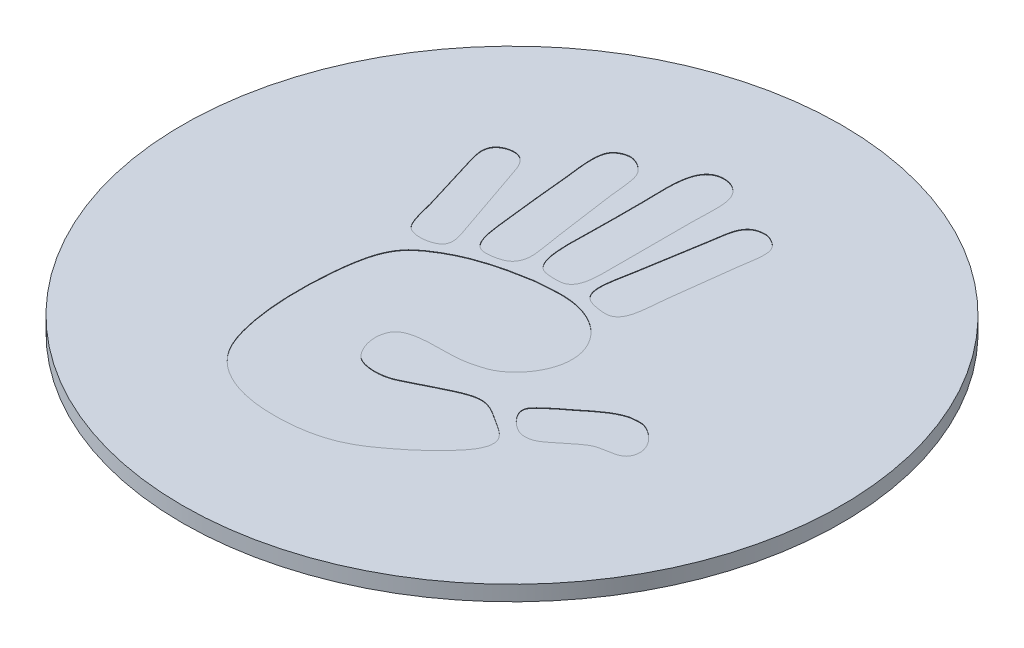
from build123d import *

# Parameters (mm, degrees)
BOSS_EXTRUDE1_DEPTH = 0.762
CUT_EXTRUDE1_DEPTH  = 1.7620001
SKETCH5_W           = 66.957021014
SKETCH5_H           = 66.705618862
SKETCH5_R           = 16.51
CUT_EXTRUDE2_DEPTH  = 1.7620001
SKETCH7_R           = 16.51
BOSS_EXTRUDE3_DEPTH = 0.7366
CUT_EXTRUDE3_DEPTH  = 0.0254


with BuildPart() as part:
    # Sketch2 → Boss-Extrude1 (new body)
    with BuildSketch(Plane(origin=(0, 0, 0), x_dir=(1, 0, 0), z_dir=(0, 1, 0))):
        with BuildLine():
            Line((-23.635380091, -2.180304698), (-14.813443938, -18.5313878))
            Line((-14.813443938, -18.5313878), (-14.014451475, -18.100305623))
            ThreePointArc((-14.014451475, -18.100305623), (-11.556001338, -17.46115621), (-9.0807022, -18.031579938))
            ThreePointArc((-9.0807022, -18.031579938), (9.738603257, -17.694307675), (20.10418165, -1.983330779))
            ThreePointArc((20.10418165, -1.983330779), (20.847910502, 0.100653492), (22.48315193, 1.591327339))
            Line((22.48315193, 1.591327339), (23.635380091, 2.212991555))
            Line((23.635380091, 2.212991555), (14.83107955, 18.5313878))
            Line((14.83107955, 18.5313878), (13.915099114, 18.037186842))
            ThreePointArc((13.915099114, 18.037186842), (11.560425994, 17.428305356), (9.192581241, 17.983763181))
            ThreePointArc((9.192581241, 17.983763181), (-9.768999321, 17.667810878), (-20.106557894, 1.76887236))
            add(Edge.make_bspline(
                [(-20.106557894, 1.76887236), (-20.133827845, 1.458762192), (-20.197178405, 1.153791884), (-20.394094427, 0.565769964), (-20.525315031, 0.288238595), (-20.771108397, -0.10343033), (-20.8619269, -0.230562624), (-21.056974515, -0.471231729), (-21.161207981, -0.585030389), (-21.49390379, -0.906948796), (-21.743736349, -1.096210535), (-22.013245148, -1.252214934)],
                knots=[0, 0, 0, 0, 0.25, 0.25, 0.5, 0.5, 0.625, 0.625, 0.75, 0.75, 1, 1, 1, 1], degree=3))
            add(Edge.make_bspline(
                [(-23.635380091, -2.180304698), (-22.82042052, -1.719446091), (-22.013245148, -1.252214934)],
                knots=[4.793026226, 4.793026226, 4.793026226, 4.83347732, 4.83347732, 4.83347732], degree=2, weights=[1, 0.999795471, 1]))
        make_face()
    extrude(amount=BOSS_EXTRUDE1_DEPTH)

    # Sketch3 → Cut-Extrude1 (cut, through all)
    with BuildSketch(Plane(origin=(0, 0.762, 0), x_dir=(1, 0, 0), z_dir=(0, 1, 0))):
        with BuildLine():
            add(Edge.make_bspline(
                [(-1.128188655, 2.734174481), (-1.869108604, 3.092326844), (-1.6328438, 5.069210065), (-1.6328438, 6.157103035), (-1.6328438, 6.906601277), (-1.6328438, 7.565510675), (-1.6328438, 8.131867521), (-1.6328438, 9.344283549), (-1.85537989, 11.072844124), (-0.755170695, 11.225651435)],
                knots=[5, 5, 5, 5, 6, 6, 6, 7, 7, 7, 8, 8, 8, 8], degree=3))
            add(Edge.make_bspline(
                [(-0.755170695, 11.225651435), (-0.219595798, 11.300048321), (0.250126056, 10.989955072), (0.407739278, 10.501578013)],
                knots=[0, 0, 0, 0, 1, 1, 1, 1], degree=3))
            add(Edge.make_bspline(
                [(0.407739278, 10.501578013), (0.565593658, 10.012511936), (0.473575097, 9.222964431), (0.473575097, 8.460994935), (0.473575097, 7.070002264), (0.473575097, 5.693186171), (0.473575097, 4.248157142), (0.473575097, 3.45375205), (0.396094848, 2.864450853), (-0.053042547, 2.690283935)],
                knots=[1, 1, 1, 1, 2, 2, 2, 3, 3, 3, 4, 4, 4, 4], degree=3))
            add(Edge.make_bspline(
                [(-0.053042547, 2.690283935), (-0.22901814, 2.622053774), (-0.871856156, 2.61027154), (-1.128188655, 2.734174481)],
                knots=[4, 4, 4, 4, 5, 5, 5, 5], degree=3))
        make_face()
        with BuildLine():
            add(Edge.make_bspline(
                [(1.746194208, 8.219631386), (1.878520413, 9.06256068), (1.899053196, 9.833005117), (2.799395044, 9.865268457)],
                knots=[7, 7, 7, 7, 8, 8, 8, 8], degree=3))
            add(Edge.make_bspline(
                [(2.799395044, 9.865268457), (3.075416276, 9.875155888), (3.532649651, 9.643886476), (3.655122876, 9.316722767)],
                knots=[0, 0, 0, 0, 1, 1, 1, 1], degree=3))
            add(Edge.make_bspline(
                [(3.655122876, 9.316722767), (3.806362668, 8.912750604), (3.630524878, 8.249758766), (3.567376236, 7.714959015)],
                knots=[1, 1, 1, 1, 2, 2, 2, 2], degree=3))
            add(Edge.make_bspline(
                [(3.567376236, 7.714959015), (3.440975599, 6.644653269), (3.312576806, 5.620391255), (3.172430229, 4.555339283)],
                knots=[2, 2, 2, 2, 3, 3, 3, 3], degree=3))
            add(Edge.make_bspline(
                [(3.172430229, 4.555339283), (3.072246786, 3.794162159), (3.134671958, 2.612114667), (2.470284855, 2.426992339)],
                knots=[3, 3, 3, 3, 4, 4, 4, 4], degree=3))
            add(Edge.make_bspline(
                [(2.470284855, 2.426992339), (2.231263973, 2.3603986), (1.566980223, 2.44745622), (1.307357656, 2.624465343)],
                knots=[4, 4, 4, 4, 5, 5, 5, 5], degree=3))
            add(Edge.make_bspline(
                [(1.307357656, 2.624465343), (0.7186249, 3.025905359), (1.079119929, 4.108475653), (1.197665743, 4.90641197)],
                knots=[5, 5, 5, 5, 6, 6, 6, 6], degree=3))
            add(Edge.make_bspline(
                [(1.197665743, 4.90641197), (1.342945516, 5.884544126), (1.593231868, 7.245461093), (1.746194208, 8.219631386)],
                knots=[6, 6, 6, 6, 7, 7, 7, 7], degree=3))
        make_face()
        with BuildLine():
            add(Edge.make_bspline(
                [(-4.616935802, 9.470305225), (-4.488709263, 9.680990178), (-4.227105765, 9.812661815), (-3.980626246, 9.843323185)],
                knots=[9, 9, 9, 9, 10, 10, 10, 10], degree=3))
            add(Edge.make_bspline(
                [(-3.980626246, 9.843323185), (-3.603990933, 9.890176514), (-3.071361594, 9.539689494), (-2.927408185, 9.141195036)],
                knots=[0, 0, 0, 0, 1, 1, 1, 1], degree=3))
            add(Edge.make_bspline(
                [(-2.927408185, 9.141195036), (-2.783592579, 8.743062314), (-2.772103178, 8.125425188), (-2.707989908, 7.671085695)],
                knots=[1, 1, 1, 1, 2, 2, 2, 2], degree=3))
            add(Edge.make_bspline(
                [(-2.707989908, 7.671085695), (-2.57624937, 6.737429752), (-2.408783168, 5.678079417), (-2.291098629, 4.708938967)],
                knots=[2, 2, 2, 2, 3, 3, 3, 3], degree=3))
            add(Edge.make_bspline(
                [(-2.291098629, 4.708938967), (-2.23175682, 4.22025185), (-2.10578682, 3.719748047), (-2.071680353, 3.260774899)],
                knots=[3, 3, 3, 3, 4, 4, 4, 4], degree=3))
            add(Edge.make_bspline(
                [(-2.071680353, 3.260774899), (-2.033439767, 2.746387352), (-2.168056962, 2.427853614), (-2.444698312, 2.251447383)],
                knots=[4, 4, 4, 4, 5, 5, 5, 5], degree=3))
            add(Edge.make_bspline(
                [(-2.444698312, 2.251447383), (-2.690781645, 2.094540406), (-3.231696444, 1.995545522), (-3.519844421, 2.053974379)],
                knots=[5, 5, 5, 5, 6, 6, 6, 6], degree=3))
            add(Edge.make_bspline(
                [(-3.519844421, 2.053974379), (-3.987361412, 2.14878347), (-4.134811596, 2.796565201), (-4.221972569, 3.52408372)],
                knots=[6, 6, 6, 6, 7, 7, 7, 7], degree=3))
            add(Edge.make_bspline(
                [(-4.221972569, 3.52408372), (-4.376898615, 4.817183938), (-4.520610868, 6.110628666), (-4.638881074, 7.407776874)],
                knots=[7, 7, 7, 7, 8, 8, 8, 8], degree=3))
            add(Edge.make_bspline(
                [(-4.638881074, 7.407776874), (-4.683719022, 7.899719608), (-4.900897984, 9.00371841), (-4.616935802, 9.470305225)],
                knots=[8, 8, 8, 8, 9, 9, 9, 9], degree=3))
        make_face()
        with BuildLine():
            add(Edge.make_bspline(
                [(-7.842374127, 6.66175818), (-7.73376742, 6.955814499), (-7.429565288, 7.115546456), (-7.118300705, 7.144485278)],
                knots=[7, 7, 7, 7, 8, 8, 8, 8], degree=3))
            add(Edge.make_bspline(
                [(-7.118300705, 7.144485278), (-6.368475178, 7.214179605), (-6.202628172, 6.378037154), (-6.021209324, 5.849920893)],
                knots=[0, 0, 0, 0, 1, 1, 1, 1], degree=3))
            add(Edge.make_bspline(
                [(-6.021209324, 5.849920893), (-5.588194987, 4.589342398), (-5.223100752, 3.49674687), (-4.792463532, 2.273392656)],
                knots=[1, 1, 1, 1, 2, 2, 2, 2], degree=3))
            add(Edge.make_bspline(
                [(-4.792463532, 2.273392656), (-4.698774099, 2.007258854), (-4.620811537, 1.656013912), (-4.748590212, 1.439610096)],
                knots=[2, 2, 2, 2, 3, 3, 3, 3], degree=3))
            add(Edge.make_bspline(
                [(-4.748590212, 1.439610096), (-4.978050949, 1.050968618), (-5.931154469, 0.946478803), (-6.284518146, 1.242137093)],
                knots=[3, 3, 3, 3, 4, 4, 4, 4], degree=3))
            add(Edge.make_bspline(
                [(-6.284518146, 1.242137093), (-6.620931942, 1.523618805), (-6.731881315, 2.301108467), (-6.876937156, 2.799993073)],
                knots=[4, 4, 4, 4, 5, 5, 5, 5], degree=3))
            add(Edge.make_bspline(
                [(-6.876937156, 2.799993073), (-7.111513863, 3.606748841), (-7.384227801, 4.435346528), (-7.644901123, 5.32330325)],
                knots=[5, 5, 5, 5, 6, 6, 6, 6], degree=3))
            add(Edge.make_bspline(
                [(-7.644901123, 5.32330325), (-7.774333446, 5.764224086), (-7.983278625, 6.280248054), (-7.842374127, 6.66175818)],
                knots=[6, 6, 6, 6, 7, 7, 7, 7], degree=3))
        make_face()
        with BuildLine():
            add(Edge.make_bspline(
                [(-0.952643699, 2.053974379), (-0.658862988, 2.100758807), (-0.370422178, 2.091629298), (-0.053042547, 2.119810198)],
                knots=[19, 19, 19, 19, 20, 20, 20, 20], degree=3))
            add(Edge.make_bspline(
                [(-0.053042547, 2.119810198), (1.549444675, 2.262092735), (2.800773083, 1.545994715), (3.260176869, 0.452227853)],
                knots=[0, 0, 0, 0, 1, 1, 1, 1], degree=3))
            add(Edge.make_bspline(
                [(3.260176869, 0.452227853), (3.847428233, -0.945878944), (2.871810999, -2.382622513), (1.921721939, -2.860974337)],
                knots=[1, 1, 1, 1, 2, 2, 2, 2], degree=3))
            add(Edge.make_bspline(
                [(1.921721939, -2.860974337), (1.66802494, -2.988753013), (1.359481985, -3.06440736), (1.022103562, -3.146228431)],
                knots=[2, 2, 2, 2, 3, 3, 3, 3], degree=3))
            add(Edge.make_bspline(
                [(1.022103562, -3.146228431), (-0.072714055, -3.411776566), (-1.984502154, -2.961398937), (-2.356917221, -3.892264351)],
                knots=[3, 3, 3, 3, 4, 4, 4, 4], degree=3))
            add(Edge.make_bspline(
                [(-2.356917221, -3.892264351), (-2.639019051, -4.597303607), (-2.222041644, -5.473736477), (-1.830316804, -5.691466655)],
                knots=[4, 4, 4, 4, 5, 5, 5, 5], degree=3))
            add(Edge.make_bspline(
                [(-1.830316804, -5.691466655), (-1.444758688, -5.905820637), (-0.812979436, -5.921530283), (-0.338279416, -5.779247746)],
                knots=[5, 5, 5, 5, 6, 6, 6, 6], degree=3))
            add(Edge.make_bspline(
                [(-0.338279416, -5.779247746), (0.066640149, -5.657876952), (0.645795533, -5.307407157), (1.241521838, -5.033211826)],
                knots=[6, 6, 6, 6, 7, 7, 7, 7], degree=3))
            add(Edge.make_bspline(
                [(1.241521838, -5.033211826), (1.74378264, -4.802080218), (2.4260498, -4.409614681), (2.974922775, -4.440792816)],
                knots=[7, 7, 7, 7, 8, 8, 8, 8], degree=3))
            add(Edge.make_bspline(
                [(2.974922775, -4.440792816), (3.431053718, -4.466699951), (3.813115059, -4.758361927), (4.203685792, -5.011301005)],
                knots=[8, 8, 8, 8, 9, 9, 9, 9], degree=3))
            add(Edge.make_bspline(
                [(4.203685792, -5.011301005), (4.563698508, -5.24443077), (5.030199195, -5.50171067), (5.10330417, -5.910884931)],
                knots=[9, 9, 9, 9, 10, 10, 10, 10], degree=3))
            add(Edge.make_bspline(
                [(5.10330417, -5.910884931), (5.197114181, -6.436055633), (4.691683889, -7.020619821), (4.401158795, -7.337120952)],
                knots=[10, 10, 10, 10, 11, 11, 11, 11], degree=3))
            add(Edge.make_bspline(
                [(4.401158795, -7.337120952), (4.006178338, -7.767379211), (3.697635382, -8.071512441), (3.304067414, -8.390321787)],
                knots=[11, 11, 11, 11, 12, 12, 12, 12], degree=3))
            add(Edge.make_bspline(
                [(3.304067414, -8.390321787), (2.464187032, -9.070659693), (1.702234761, -9.687676701), (0.605212282, -10.014030812)],
                knots=[12, 12, 12, 12, 13, 13, 13, 13], degree=3))
            add(Edge.make_bspline(
                [(0.605212282, -10.014030812), (-0.608960746, -10.375214861), (-2.162079718, -10.396540016), (-3.256535599, -10.123722724)],
                knots=[13, 13, 13, 13, 14, 14, 14, 14], degree=3))
            add(Edge.make_bspline(
                [(-3.256535599, -10.123722724), (-4.395571045, -9.839812218), (-5.282442561, -9.231821366), (-5.735972455, -8.280629875)],
                knots=[14, 14, 14, 14, 15, 15, 15, 15], degree=3))
            add(Edge.make_bspline(
                [(-5.735972455, -8.280629875), (-6.387802177, -6.913511732), (-6.541177929, -4.60305692), (-6.350336739, -2.597699966)],
                knots=[15, 15, 15, 15, 16, 16, 16, 16], degree=3))
            add(Edge.make_bspline(
                [(-6.350336739, -2.597699966), (-6.245226806, -1.493270527), (-6.087200172, -0.53534387), (-5.538482226, 0.123100439)],
                knots=[16, 16, 16, 16, 17, 17, 17, 17], degree=3))
            add(Edge.make_bspline(
                [(-5.538482226, 0.123100439), (-5.279307522, 0.434123865), (-4.865396252, 0.713314587), (-4.485281391, 0.934937726)],
                knots=[17, 17, 17, 17, 18, 18, 18, 18], degree=3))
            add(Edge.make_bspline(
                [(-4.485281391, 0.934937726), (-3.476711797, 1.523015913), (-2.341948272, 1.832747427), (-0.952643699, 2.053974379)],
                knots=[18, 18, 18, 18, 19, 19, 19, 19], degree=3))
        make_face()
        with BuildLine():
            add(Edge.make_bspline(
                [(7.363288299, -1.478663313), (7.426850352, -1.461334471), (7.480766132, -1.466881078), (7.560761302, -1.45671804)],
                knots=[9, 9, 9, 9, 10, 10, 10, 10], degree=3))
            add(Edge.make_bspline(
                [(7.560761302, -1.45671804), (7.641307688, -1.446486099), (7.860967121, -1.412448534), (8.0434884, -1.45671804)],
                knots=[0, 0, 0, 0, 1, 1, 1, 1], degree=3))
            add(Edge.make_bspline(
                [(8.0434884, -1.45671804), (8.571794141, -1.584841225), (9.476545714, -2.402018414), (9.074778414, -3.146228431)],
                knots=[1, 1, 1, 1, 2, 2, 2, 2], degree=3))
            add(Edge.make_bspline(
                [(9.074778414, -3.146228431), (8.859563157, -3.544791791), (8.119349453, -3.467104836), (7.714378211, -3.650900802)],
                knots=[2, 2, 2, 2, 3, 3, 3, 3], degree=3))
            add(Edge.make_bspline(
                [(7.714378211, -3.650900802), (7.389333238, -3.798419888), (7.060636461, -4.116781372), (6.770869288, -4.331100903)],
                knots=[3, 3, 3, 3, 4, 4, 4, 4], degree=3))
            add(Edge.make_bspline(
                [(6.770869288, -4.331100903), (6.362418498, -4.633167075), (6.022731859, -5.057844275), (5.388523813, -4.923519914)],
                knots=[4, 4, 4, 4, 5, 5, 5, 5], degree=3))
            add(Edge.make_bspline(
                [(5.388523813, -4.923519914), (4.995679316, -4.840286352), (4.371909916, -4.271845222), (4.379213523, -3.848373805)],
                knots=[5, 5, 5, 5, 6, 6, 6, 6], degree=3))
            add(Edge.make_bspline(
                [(4.379213523, -3.848373805), (4.384140013, -3.562568495), (4.684621439, -3.365818962), (4.971632533, -3.102337886)],
                knots=[6, 6, 6, 6, 7, 7, 7, 7], degree=3))
            add(Edge.make_bspline(
                [(4.971632533, -3.102337886), (5.217026847, -2.877097394), (5.505105921, -2.684206371), (5.717668453, -2.509918875)],
                knots=[7, 7, 7, 7, 8, 8, 8, 8], degree=3))
            add(Edge.make_bspline(
                [(5.717668453, -2.509918875), (6.219722549, -2.098264144), (6.741000291, -1.648231024), (7.363288299, -1.478663313)],
                knots=[8, 8, 8, 8, 9, 9, 9, 9], degree=3))
        make_face()
    extrude(amount=-CUT_EXTRUDE1_DEPTH, mode=Mode.SUBTRACT)

    # Sketch5 → Cut-Extrude2 (cut, through all)
    with BuildSketch(Plane(origin=(0, 0.762, 0), x_dir=(1, 0, 0), z_dir=(0, 1, 0))):
        with Locations((3.630515315, 0.386297247)):
            Rectangle(SKETCH5_W, SKETCH5_H)
        with Locations((0.008817806, 0)):
            Circle(SKETCH5_R, mode=Mode.SUBTRACT)
    extrude(amount=-CUT_EXTRUDE2_DEPTH, mode=Mode.SUBTRACT)

    # Sketch7 → Boss-Extrude3 (add)
    with BuildSketch(Plane(origin=(0, 0.762, 0), x_dir=(1, 0, 0), z_dir=(0, 1, 0))):
        with Locations((0.008817806, 0)):
            Circle(SKETCH7_R)
    extrude(amount=-BOSS_EXTRUDE3_DEPTH)

    # Sketch9 → Cut-Extrude3 (cut)
    with BuildSketch(Plane(origin=(0, 0.762, 0), x_dir=(1, 0, 0), z_dir=(0, 1, 0))):
        with BuildLine():
            add(Edge.make_bspline(
                [(1.197665743, 4.90641197), (1.079119929, 4.108475653), (0.7186249, 3.025905359), (1.307357656, 2.624465343)],
                knots=[5, 5, 5, 5, 6, 6, 6, 6], degree=3))
            add(Edge.make_bspline(
                [(1.307357656, 2.624465343), (1.566980223, 2.44745622), (2.231263973, 2.3603986), (2.470284855, 2.426992339)],
                knots=[4, 4, 4, 4, 5, 5, 5, 5], degree=3))
            add(Edge.make_bspline(
                [(2.470284855, 2.426992339), (3.134671958, 2.612114667), (3.072246786, 3.794162159), (3.172430229, 4.555339283)],
                knots=[3, 3, 3, 3, 4, 4, 4, 4], degree=3))
            add(Edge.make_bspline(
                [(3.172430229, 4.555339283), (3.312576806, 5.620391255), (3.440975599, 6.644653269), (3.567376236, 7.714959015)],
                knots=[2, 2, 2, 2, 3, 3, 3, 3], degree=3))
            add(Edge.make_bspline(
                [(3.567376236, 7.714959015), (3.630524878, 8.249758766), (3.806362668, 8.912750604), (3.655122876, 9.316722767)],
                knots=[1, 1, 1, 1, 2, 2, 2, 2], degree=3))
            add(Edge.make_bspline(
                [(3.655122876, 9.316722767), (3.532649651, 9.643886476), (3.075416276, 9.875155888), (2.799395044, 9.865268457)],
                knots=[0, 0, 0, 0, 1, 1, 1, 1], degree=3))
            add(Edge.make_bspline(
                [(2.799395044, 9.865268457), (1.899053196, 9.833005117), (1.878520413, 9.06256068), (1.746194208, 8.219631386)],
                knots=[7, 7, 7, 7, 8, 8, 8, 8], degree=3))
            add(Edge.make_bspline(
                [(1.746194208, 8.219631386), (1.593231868, 7.245461093), (1.342945516, 5.884544126), (1.197665743, 4.90641197)],
                knots=[6, 6, 6, 6, 7, 7, 7, 7], degree=3))
        make_face()
        with BuildLine():
            add(Edge.make_bspline(
                [(-0.053042547, 2.690283935), (0.396094848, 2.864450853), (0.473575097, 3.45375205), (0.473575097, 4.248157142), (0.473575097, 5.693186171), (0.473575097, 7.070002264), (0.473575097, 8.460994935), (0.473575097, 9.222964431), (0.565593658, 10.012511936), (0.407739278, 10.501578013)],
                knots=[1, 1, 1, 1, 2, 2, 2, 3, 3, 3, 4, 4, 4, 4], degree=3))
            add(Edge.make_bspline(
                [(0.407739278, 10.501578013), (0.250126056, 10.989955072), (-0.219595798, 11.300048321), (-0.755170695, 11.225651435)],
                knots=[0, 0, 0, 0, 1, 1, 1, 1], degree=3))
            add(Edge.make_bspline(
                [(-0.755170695, 11.225651435), (-1.85537989, 11.072844124), (-1.6328438, 9.344283549), (-1.6328438, 8.131867521), (-1.6328438, 7.565510675), (-1.6328438, 6.906601277), (-1.6328438, 6.157103035), (-1.6328438, 5.069210065), (-1.869108604, 3.092326844), (-1.128188655, 2.734174481)],
                knots=[5, 5, 5, 5, 6, 6, 6, 7, 7, 7, 8, 8, 8, 8], degree=3))
            add(Edge.make_bspline(
                [(-1.128188655, 2.734174481), (-0.871856156, 2.61027154), (-0.22901814, 2.622053774), (-0.053042547, 2.690283935)],
                knots=[4, 4, 4, 4, 5, 5, 5, 5], degree=3))
        make_face()
        with BuildLine():
            add(Edge.make_bspline(
                [(-4.638881074, 7.407776874), (-4.520610868, 6.110628666), (-4.376898615, 4.817183938), (-4.221972569, 3.52408372)],
                knots=[7, 7, 7, 7, 8, 8, 8, 8], degree=3))
            add(Edge.make_bspline(
                [(-4.221972569, 3.52408372), (-4.134811596, 2.796565201), (-3.987361412, 2.14878347), (-3.519844421, 2.053974379)],
                knots=[6, 6, 6, 6, 7, 7, 7, 7], degree=3))
            add(Edge.make_bspline(
                [(-3.519844421, 2.053974379), (-3.231696444, 1.995545522), (-2.690781645, 2.094540406), (-2.444698312, 2.251447383)],
                knots=[5, 5, 5, 5, 6, 6, 6, 6], degree=3))
            add(Edge.make_bspline(
                [(-2.444698312, 2.251447383), (-2.168056962, 2.427853614), (-2.033439767, 2.746387352), (-2.071680353, 3.260774899)],
                knots=[4, 4, 4, 4, 5, 5, 5, 5], degree=3))
            add(Edge.make_bspline(
                [(-2.071680353, 3.260774899), (-2.10578682, 3.719748047), (-2.23175682, 4.22025185), (-2.291098629, 4.708938967)],
                knots=[3, 3, 3, 3, 4, 4, 4, 4], degree=3))
            add(Edge.make_bspline(
                [(-2.291098629, 4.708938967), (-2.408783168, 5.678079417), (-2.57624937, 6.737429752), (-2.707989908, 7.671085695)],
                knots=[2, 2, 2, 2, 3, 3, 3, 3], degree=3))
            add(Edge.make_bspline(
                [(-2.707989908, 7.671085695), (-2.772103178, 8.125425188), (-2.783592579, 8.743062314), (-2.927408185, 9.141195036)],
                knots=[1, 1, 1, 1, 2, 2, 2, 2], degree=3))
            add(Edge.make_bspline(
                [(-2.927408185, 9.141195036), (-3.071361594, 9.539689494), (-3.603990933, 9.890176514), (-3.980626246, 9.843323185)],
                knots=[0, 0, 0, 0, 1, 1, 1, 1], degree=3))
            add(Edge.make_bspline(
                [(-3.980626246, 9.843323185), (-4.227105765, 9.812661815), (-4.488709263, 9.680990178), (-4.616935802, 9.470305225)],
                knots=[9, 9, 9, 9, 10, 10, 10, 10], degree=3))
            add(Edge.make_bspline(
                [(-4.616935802, 9.470305225), (-4.900897984, 9.00371841), (-4.683719022, 7.899719608), (-4.638881074, 7.407776874)],
                knots=[8, 8, 8, 8, 9, 9, 9, 9], degree=3))
        make_face()
        with BuildLine():
            add(Edge.make_bspline(
                [(-7.644901123, 5.32330325), (-7.384227801, 4.435346528), (-7.111513863, 3.606748841), (-6.876937156, 2.799993073)],
                knots=[5, 5, 5, 5, 6, 6, 6, 6], degree=3))
            add(Edge.make_bspline(
                [(-6.876937156, 2.799993073), (-6.731881315, 2.301108467), (-6.620931942, 1.523618805), (-6.284518146, 1.242137093)],
                knots=[4, 4, 4, 4, 5, 5, 5, 5], degree=3))
            add(Edge.make_bspline(
                [(-6.284518146, 1.242137093), (-5.931154469, 0.946478803), (-4.978050949, 1.050968618), (-4.748590212, 1.439610096)],
                knots=[3, 3, 3, 3, 4, 4, 4, 4], degree=3))
            add(Edge.make_bspline(
                [(-4.748590212, 1.439610096), (-4.620811537, 1.656013912), (-4.698774099, 2.007258854), (-4.792463532, 2.273392656)],
                knots=[2, 2, 2, 2, 3, 3, 3, 3], degree=3))
            add(Edge.make_bspline(
                [(-4.792463532, 2.273392656), (-5.223100752, 3.49674687), (-5.588194987, 4.589342398), (-6.021209324, 5.849920893)],
                knots=[1, 1, 1, 1, 2, 2, 2, 2], degree=3))
            add(Edge.make_bspline(
                [(-6.021209324, 5.849920893), (-6.202628172, 6.378037154), (-6.368475178, 7.214179605), (-7.118300705, 7.144485278)],
                knots=[0, 0, 0, 0, 1, 1, 1, 1], degree=3))
            add(Edge.make_bspline(
                [(-7.118300705, 7.144485278), (-7.429565288, 7.115546456), (-7.73376742, 6.955814499), (-7.842374127, 6.66175818)],
                knots=[7, 7, 7, 7, 8, 8, 8, 8], degree=3))
            add(Edge.make_bspline(
                [(-7.842374127, 6.66175818), (-7.983278625, 6.280248054), (-7.774333446, 5.764224086), (-7.644901123, 5.32330325)],
                knots=[6, 6, 6, 6, 7, 7, 7, 7], degree=3))
        make_face()
        with BuildLine():
            add(Edge.make_bspline(
                [(-4.485281391, 0.934937726), (-4.865396252, 0.713314587), (-5.279307522, 0.434123865), (-5.538482226, 0.123100439)],
                knots=[17, 17, 17, 17, 18, 18, 18, 18], degree=3))
            add(Edge.make_bspline(
                [(-5.538482226, 0.123100439), (-6.087200172, -0.53534387), (-6.245226806, -1.493270527), (-6.350336739, -2.597699966)],
                knots=[16, 16, 16, 16, 17, 17, 17, 17], degree=3))
            add(Edge.make_bspline(
                [(-6.350336739, -2.597699966), (-6.541177929, -4.60305692), (-6.387802177, -6.913511732), (-5.735972455, -8.280629875)],
                knots=[15, 15, 15, 15, 16, 16, 16, 16], degree=3))
            add(Edge.make_bspline(
                [(-5.735972455, -8.280629875), (-5.282442561, -9.231821366), (-4.395571045, -9.839812218), (-3.256535599, -10.123722724)],
                knots=[14, 14, 14, 14, 15, 15, 15, 15], degree=3))
            add(Edge.make_bspline(
                [(-3.256535599, -10.123722724), (-2.162079718, -10.396540016), (-0.608960746, -10.375214861), (0.605212282, -10.014030812)],
                knots=[13, 13, 13, 13, 14, 14, 14, 14], degree=3))
            add(Edge.make_bspline(
                [(0.605212282, -10.014030812), (1.702234761, -9.687676701), (2.464187032, -9.070659693), (3.304067414, -8.390321787)],
                knots=[12, 12, 12, 12, 13, 13, 13, 13], degree=3))
            add(Edge.make_bspline(
                [(3.304067414, -8.390321787), (3.697635382, -8.071512441), (4.006178338, -7.767379211), (4.401158795, -7.337120952)],
                knots=[11, 11, 11, 11, 12, 12, 12, 12], degree=3))
            add(Edge.make_bspline(
                [(4.401158795, -7.337120952), (4.691683889, -7.020619821), (5.197114181, -6.436055633), (5.10330417, -5.910884931)],
                knots=[10, 10, 10, 10, 11, 11, 11, 11], degree=3))
            add(Edge.make_bspline(
                [(5.10330417, -5.910884931), (5.030199195, -5.50171067), (4.563698508, -5.24443077), (4.203685792, -5.011301005)],
                knots=[9, 9, 9, 9, 10, 10, 10, 10], degree=3))
            add(Edge.make_bspline(
                [(4.203685792, -5.011301005), (3.813115059, -4.758361927), (3.431053718, -4.466699951), (2.974922775, -4.440792816)],
                knots=[8, 8, 8, 8, 9, 9, 9, 9], degree=3))
            add(Edge.make_bspline(
                [(2.974922775, -4.440792816), (2.4260498, -4.409614681), (1.74378264, -4.802080218), (1.241521838, -5.033211826)],
                knots=[7, 7, 7, 7, 8, 8, 8, 8], degree=3))
            add(Edge.make_bspline(
                [(1.241521838, -5.033211826), (0.645795533, -5.307407157), (0.066640149, -5.657876952), (-0.338279416, -5.779247746)],
                knots=[6, 6, 6, 6, 7, 7, 7, 7], degree=3))
            add(Edge.make_bspline(
                [(-0.338279416, -5.779247746), (-0.812979436, -5.921530283), (-1.444758688, -5.905820637), (-1.830316804, -5.691466655)],
                knots=[5, 5, 5, 5, 6, 6, 6, 6], degree=3))
            add(Edge.make_bspline(
                [(-1.830316804, -5.691466655), (-2.222041644, -5.473736477), (-2.639019051, -4.597303607), (-2.356917221, -3.892264351)],
                knots=[4, 4, 4, 4, 5, 5, 5, 5], degree=3))
            add(Edge.make_bspline(
                [(-2.356917221, -3.892264351), (-1.984502154, -2.961398937), (-0.072714055, -3.411776566), (1.022103562, -3.146228431)],
                knots=[3, 3, 3, 3, 4, 4, 4, 4], degree=3))
            add(Edge.make_bspline(
                [(1.022103562, -3.146228431), (1.359481985, -3.06440736), (1.66802494, -2.988753013), (1.921721939, -2.860974337)],
                knots=[2, 2, 2, 2, 3, 3, 3, 3], degree=3))
            add(Edge.make_bspline(
                [(1.921721939, -2.860974337), (2.871810999, -2.382622513), (3.847428233, -0.945878944), (3.260176869, 0.452227853)],
                knots=[1, 1, 1, 1, 2, 2, 2, 2], degree=3))
            add(Edge.make_bspline(
                [(3.260176869, 0.452227853), (2.800773083, 1.545994715), (1.549444675, 2.262092735), (-0.053042547, 2.119810198)],
                knots=[0, 0, 0, 0, 1, 1, 1, 1], degree=3))
            add(Edge.make_bspline(
                [(-0.053042547, 2.119810198), (-0.370422178, 2.091629298), (-0.658862988, 2.100758807), (-0.952643699, 2.053974379)],
                knots=[19, 19, 19, 19, 20, 20, 20, 20], degree=3))
            add(Edge.make_bspline(
                [(-0.952643699, 2.053974379), (-2.341948272, 1.832747427), (-3.476711797, 1.523015913), (-4.485281391, 0.934937726)],
                knots=[18, 18, 18, 18, 19, 19, 19, 19], degree=3))
        make_face()
        with BuildLine():
            add(Edge.make_bspline(
                [(5.717668453, -2.509918875), (5.505105921, -2.684206371), (5.217026847, -2.877097394), (4.971632533, -3.102337886)],
                knots=[7, 7, 7, 7, 8, 8, 8, 8], degree=3))
            add(Edge.make_bspline(
                [(4.971632533, -3.102337886), (4.684621439, -3.365818962), (4.384140013, -3.562568495), (4.379213523, -3.848373805)],
                knots=[6, 6, 6, 6, 7, 7, 7, 7], degree=3))
            add(Edge.make_bspline(
                [(4.379213523, -3.848373805), (4.371909916, -4.271845222), (4.995679316, -4.840286352), (5.388523813, -4.923519914)],
                knots=[5, 5, 5, 5, 6, 6, 6, 6], degree=3))
            add(Edge.make_bspline(
                [(5.388523813, -4.923519914), (6.022731859, -5.057844275), (6.362418498, -4.633167075), (6.770869288, -4.331100903)],
                knots=[4, 4, 4, 4, 5, 5, 5, 5], degree=3))
            add(Edge.make_bspline(
                [(6.770869288, -4.331100903), (7.060636461, -4.116781372), (7.389333238, -3.798419888), (7.714378211, -3.650900802)],
                knots=[3, 3, 3, 3, 4, 4, 4, 4], degree=3))
            add(Edge.make_bspline(
                [(7.714378211, -3.650900802), (8.119349453, -3.467104836), (8.859563157, -3.544791791), (9.074778414, -3.146228431)],
                knots=[2, 2, 2, 2, 3, 3, 3, 3], degree=3))
            add(Edge.make_bspline(
                [(9.074778414, -3.146228431), (9.476545714, -2.402018414), (8.571794141, -1.584841225), (8.0434884, -1.45671804)],
                knots=[1, 1, 1, 1, 2, 2, 2, 2], degree=3))
            add(Edge.make_bspline(
                [(8.0434884, -1.45671804), (7.860967121, -1.412448534), (7.641307688, -1.446486099), (7.560761302, -1.45671804)],
                knots=[0, 0, 0, 0, 1, 1, 1, 1], degree=3))
            add(Edge.make_bspline(
                [(7.560761302, -1.45671804), (7.480766132, -1.466881078), (7.426850352, -1.461334471), (7.363288299, -1.478663313)],
                knots=[9, 9, 9, 9, 10, 10, 10, 10], degree=3))
            add(Edge.make_bspline(
                [(7.363288299, -1.478663313), (6.741000291, -1.648231024), (6.219722549, -2.098264144), (5.717668453, -2.509918875)],
                knots=[8, 8, 8, 8, 9, 9, 9, 9], degree=3))
        make_face()
    extrude(amount=-CUT_EXTRUDE3_DEPTH, mode=Mode.SUBTRACT)


solid = part.part
